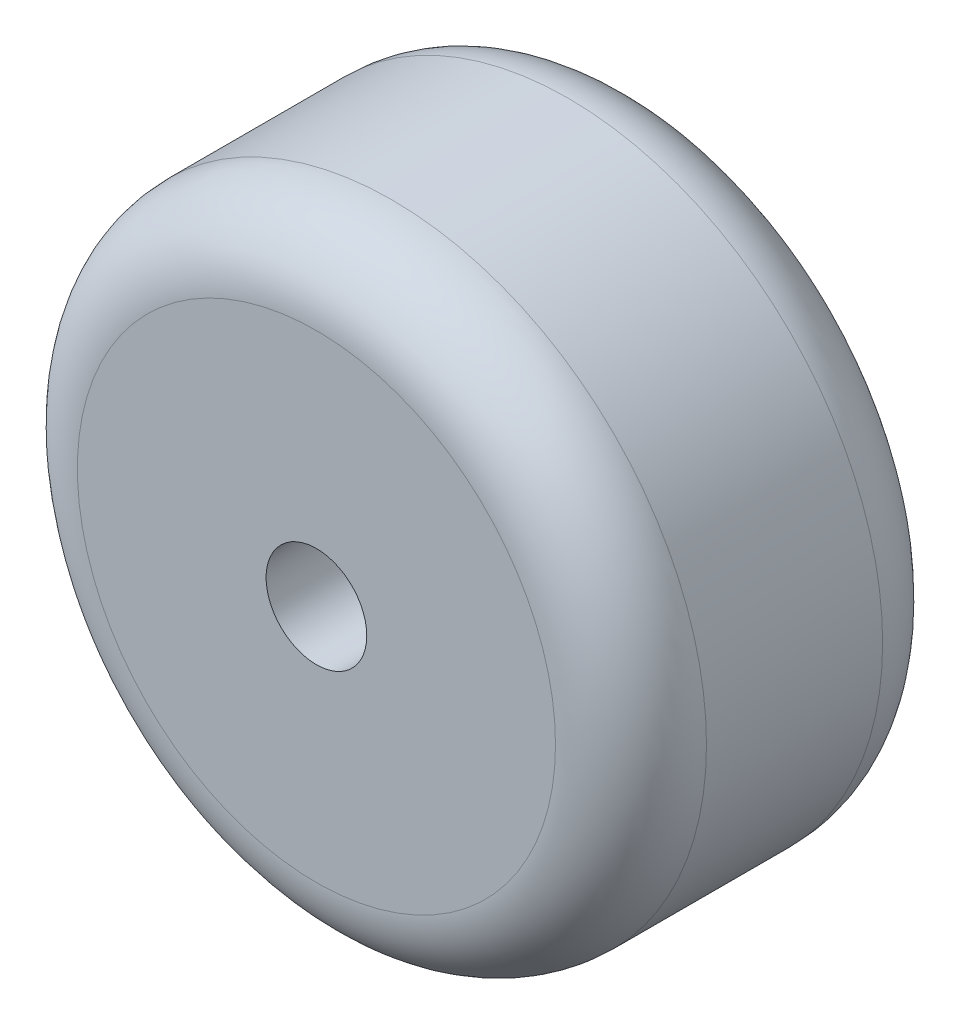
from build123d import *

# Parameters (mm, degrees)
SKETCH2_R               = 2
CUT_EXTRUDE1_DEPTH      = 1
CUT_EXTRUDE1_DEPTH_BACK = 14


with BuildPart() as part:
    # Sketch1 → Revolve1 (revolve)
    with BuildSketch(Plane(origin=(0, 0, 0), x_dir=(1, 0, 0), z_dir=(0, 1, 0))):
        with BuildLine():
            Line((0, -6.5), (9.5, -6.5))
            ThreePointArc((9.5, -6.5), (11.621320344, -5.621320344), (12.5, -3.5))
            Line((12.5, -3.5), (12.5, 3.5))
            ThreePointArc((12.5, 3.5), (11.621320344, 5.621320344), (9.5, 6.5))
            Line((9.5, 6.5), (0, 6.5))
            Line((0, 6.5), (0, -6.5))
        make_face()
    revolve(axis=Axis((0, 0, 6.5), (0, 0, -1)))

    # Sketch2 → Cut-Extrude1 (cut, two sides)
    with BuildSketch(Plane.XY.offset(6.5)) as cut_extrude1_sk:
        Circle(SKETCH2_R)
    extrude(amount=CUT_EXTRUDE1_DEPTH, mode=Mode.SUBTRACT)
    extrude(cut_extrude1_sk.sketch, amount=-CUT_EXTRUDE1_DEPTH_BACK, mode=Mode.SUBTRACT)


solid = part.part
